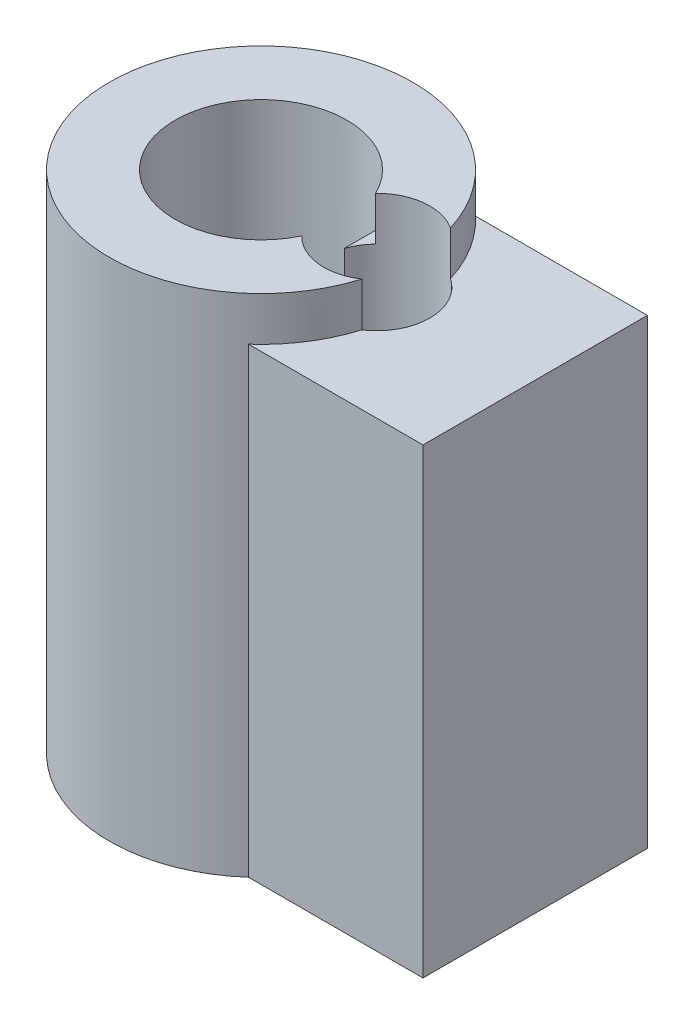
from build123d import *

# Parameters (mm, degrees)
SKETCH1_R               = 6
BOSS_EXTRUDE1_DEPTH     = 20
SKETCH2_R               = 3.4
CUT_EXTRUDE1_DEPTH      = 13.55
SKETCH5_W               = 8.287891014
SKETCH5_H               = 8.876063753
BOSS_EXTRUDE2_DEPTH     = 18.26
SKETCH8_R               = 2.1
CUT_EXTRUDE6_DEPTH      = 30
CUT_EXTRUDE6_DEPTH_BACK = 30


with BuildPart() as part:
    # Sketch1 → Boss-Extrude1 (new body)
    with BuildSketch(Plane(origin=(0, 0, 0), x_dir=(1, 0, 0), z_dir=(0, 1, 0))):
        Circle(SKETCH1_R)
    extrude(amount=BOSS_EXTRUDE1_DEPTH)

    # Sketch2 → Cut-Extrude1 (cut)
    with BuildSketch(Plane(origin=(0, 20, 0), x_dir=(1, 0, 0), z_dir=(0, 1, 0))):
        Circle(SKETCH2_R)
    extrude(amount=-CUT_EXTRUDE1_DEPTH, mode=Mode.SUBTRACT)

    # Sketch5 → Boss-Extrude2 (add)
    with BuildSketch(Plane(origin=(0, 18.26, 0), x_dir=(1, 0, 0), z_dir=(0, 1, 0))):
        with Locations((6.743945507, -0.04378733)):
            Rectangle(SKETCH5_W, SKETCH5_H)
    extrude(amount=-BOSS_EXTRUDE2_DEPTH)

    # Sketch8 → Cut-Extrude6 (cut, two sides)
    with BuildSketch(Plane(origin=(0, 18.26, 0), x_dir=(1, 0, 0), z_dir=(0, 1, 0))) as cut_extrude6_sk:
        with Locations((4.580522752, 0)):
            Circle(SKETCH8_R)
    extrude(amount=CUT_EXTRUDE6_DEPTH, mode=Mode.SUBTRACT)
    extrude(cut_extrude6_sk.sketch, amount=-CUT_EXTRUDE6_DEPTH_BACK, mode=Mode.SUBTRACT)


solid = part.part
